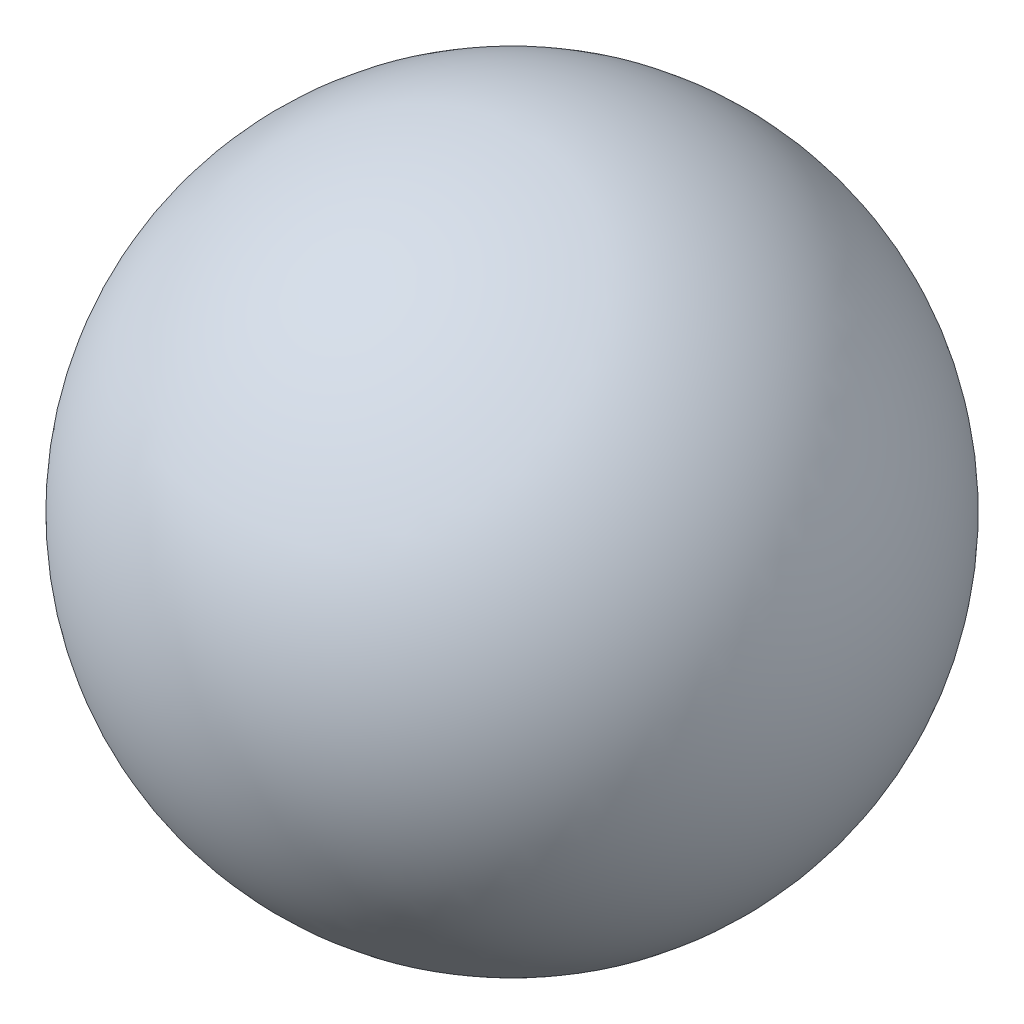
from build123d import *


with BuildPart() as part:
    # Sketch1 → Revolve3 (revolve)
    with BuildSketch(Plane.XY):
        with BuildLine():
            Line((0, 10), (0, -10))
            ThreePointArc((0, -10), (10, 0), (0, 10))
        make_face()
    revolve(axis=Axis((0, 10, 0), (0, -1, 0)))


solid = part.part
